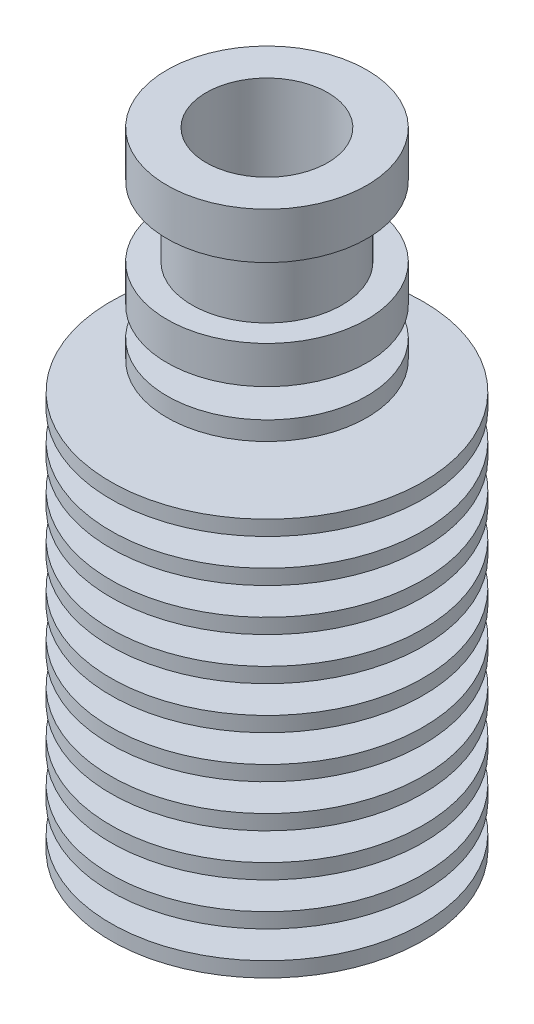
from build123d import *


with BuildPart() as part:
    # Sketch1 → Revolve1 (revolve)
    with BuildSketch(Plane.XY):
        Polygon((3, -25.05), (12.5, -25.05), (12.5, -23.85), (7.5, -23.85), (7.5, -21.65), (12.5, -21.65), (12.5, -20.45), (7.5, -20.45), (7.5, -18.25), (12.5, -18.25), (12.5, -17.05), (7.5, -17.05), (7.5, -14.85), (12.5, -14.85), (12.5, -13.65), (7.5, -13.65), (7.5, -11.45), (12.5, -11.45), (12.5, -10.25), (7.5, -10.25), (7.5, -8.05), (12.5, -8.05), (12.5, -6.85), (6.5, -6.85), (6.5, -4.65), (12.5, -4.65), (12.5, -3.45), (4.5, -3.45), (4.5, -1.25), (12.5, -1.25), (12.5, -0.05), (4.5, -0.05), (4.5, 2.15), (12.5, 2.15), (12.5, 3.35), (4.5, 3.35), (4.5, 5.55), (12.5, 5.55), (12.5, 6.75), (4.5, 6.75), (4.5, 8.95), (8, 8.95), (8, 10.45), (4.5, 10.45), (4.5, 12.75), (8, 12.75), (8, 15.75), (6, 15.75), (6, 21.35), (8, 21.35), (8, 25.05), (4.8641, 25.05), (4.8641, 15.05), (2, 10.089233282), (2, 6.089233282), (1, 5.511883013), (1, -5.895299462), (3, -7.05), align=None)
    revolve(axis=Axis((0, -25.05, 0), (0, 1, 0)))


solid = part.part
